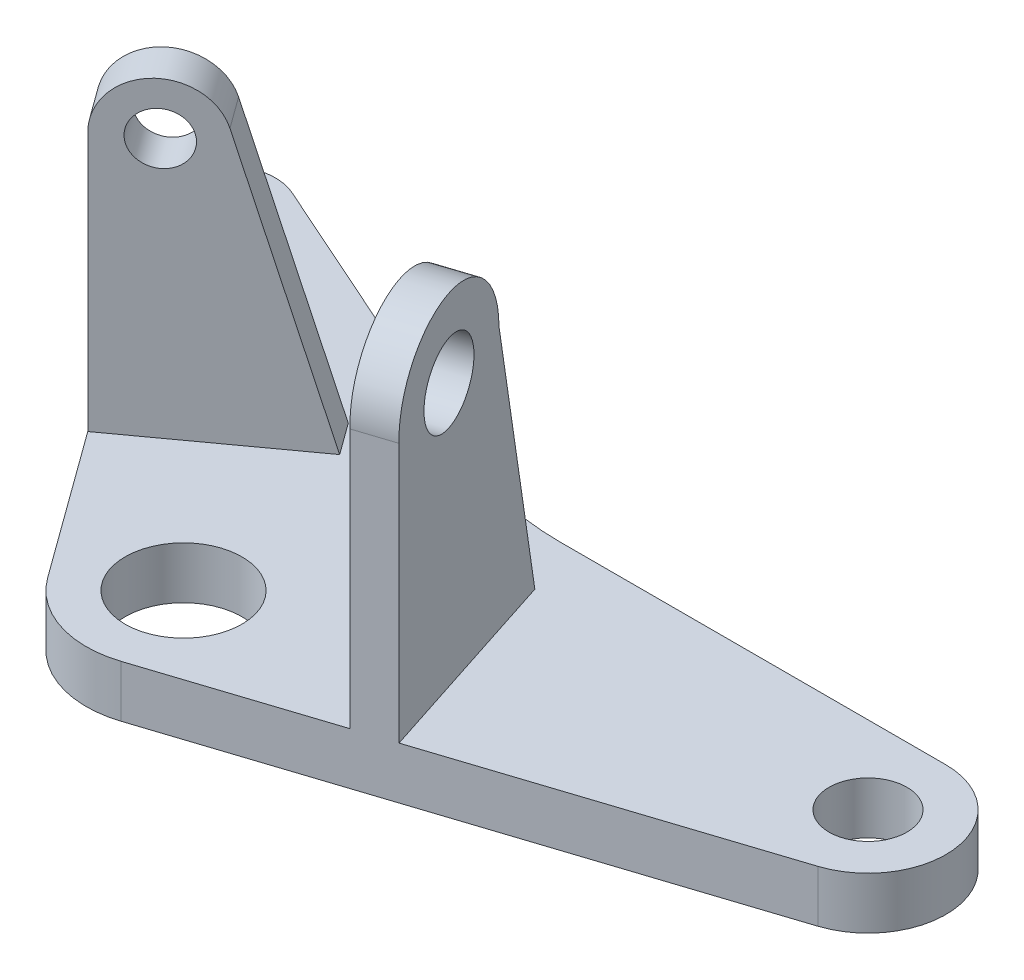
from build123d import *

# Parameters (mm, degrees)
BOSS_EXTRUDE1_DEPTH = 8
SKETCH3_R           = 6
SKETCH3_R_2         = 4
SKETCH3_R_3         = 9
CUT_EXTRUDE1_DEPTH  = 34
SKETCH5_R           = 6
BOSS_EXTRUDE2_DEPTH = 6
SKETCH6_R           = 4
BOSS_EXTRUDE3_DEPTH = 6


with BuildPart() as part:
    # Sketch2 → Boss-Extrude1 (new body)
    with BuildSketch(Plane(origin=(0, 0, 0), x_dir=(1, 0, 0), z_dir=(0, 1, 0))):
        with BuildLine():
            Line((14.773677032, 0), (74.248108018, 0))
            ThreePointArc((74.248108018, 0), (86.100368105, -10.12278642), (77.956311951, -23.412678196))
            Line((77.956311951, -23.412678196), (-3.116637066, -49.754876163))
            ThreePointArc((-3.116637066, -49.754876163), (-12.387146898, -49.754876163), (-19.887146898, -44.305807203))
            Line((-19.887146898, -44.305807203), (-62.224027937, 13.965910429))
            ThreePointArc((-62.224027937, 13.965910429), (-61.969059674, 23.702755576), (-52.497998837, 25.976556108))
            Line((-52.497998837, 25.976556108), (-2.309261977, 3.631090779))
            ThreePointArc((-2.309261977, 3.631090779), (6.041386017, 0.917800769), (14.773677032, 0))
        make_face()
    extrude(amount=BOSS_EXTRUDE1_DEPTH)

    # Sketch3 → Cut-Extrude1 (cut)
    with BuildSketch(Plane(origin=(0, 8, 0), x_dir=(1, 0, 0), z_dir=(0, 1, 0))):
        with Locations((74.248108018, -12)):
            Circle(SKETCH3_R)
        with Locations((-55.751891982, 18.668192447)):
            Circle(SKETCH3_R_2)
        with Locations((-7.751891982, -35.489028418)):
            Circle(SKETCH3_R_3)
    extrude(amount=-CUT_EXTRUDE1_DEPTH, mode=Mode.SUBTRACT)

    # Sketch5 → Boss-Extrude2 (add)
    with BuildSketch(Plane(origin=(14.894305626, 0, -4.83945326), x_dir=(-0.309016994, 0, -0.951056516), z_dir=(0.951056516, 0, -0.309016994))):
        with BuildLine():
            Line((-46.356605373, 8), (-46.356605373, 48))
            ThreePointArc((-46.356605373, 48), (-34.62942849, 60.519891788), (-22.367996489, 48.522739904))
            Line((-22.367996489, 48.522739904), (-13.754622225, 8))
            Line((-13.754622225, 8), (-46.356605373, 8))
        make_face()
        with Locations((-34.367996489, 48.522739904)):
            Circle(SKETCH5_R, mode=Mode.SUBTRACT)
    extrude(amount=-BOSS_EXTRUDE2_DEPTH)

    # Sketch6 → Boss-Extrude3 (add)
    with BuildSketch(Plane(origin=(-5.786875521, 0, -7.964950844), x_dir=(0.809016994, 0, -0.587785252), z_dir=(0.587785252, 0, 0.809016994))):
        with BuildLine():
            Line((-42.131339875, 8), (-42.131339875, 46))
            Line((-42.131339875, 46), (-42.131339875, 48))
            ThreePointArc((-42.131339875, 48), (-35.244724682, 55.92214455), (-26.441246307, 50.205098847))
            Line((-26.441246307, 50.205098847), (-14.339128957, 8))
            Line((-14.339128957, 8), (-42.131339875, 8))
        make_face()
        with Locations((-34.131339875, 48)):
            Circle(SKETCH6_R, mode=Mode.SUBTRACT)
    extrude(amount=BOSS_EXTRUDE3_DEPTH)


solid = part.part
